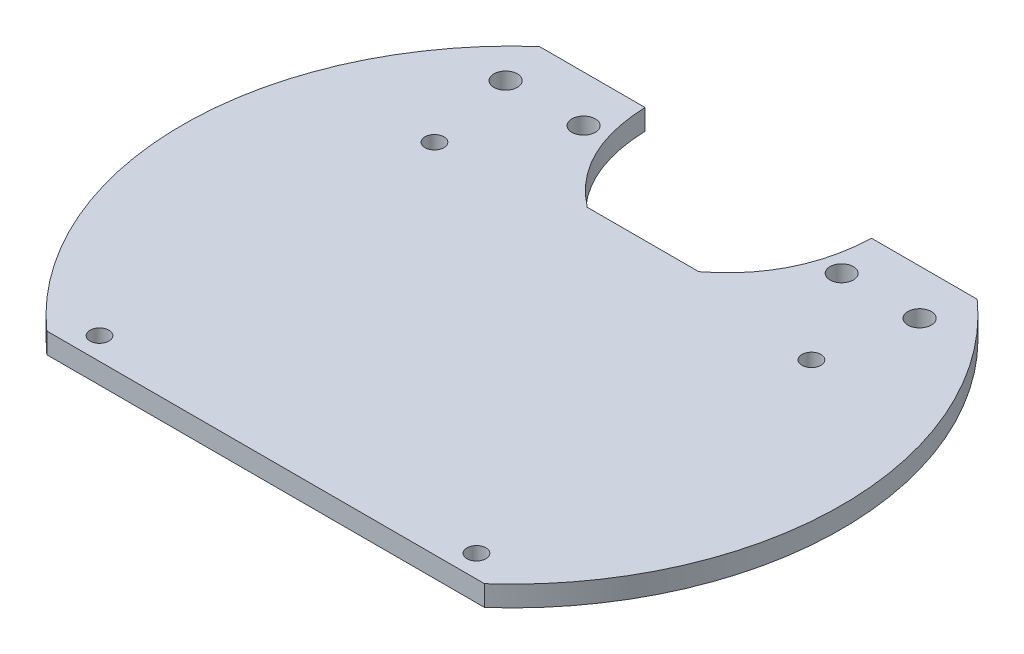
from build123d import *

# Parameters (mm, degrees)
SKETCH1_R           = 50.8
BOSS_EXTRUDE1_DEPTH = 3.175
SKETCH2_W           = 114.887790664
SKETCH2_H           = 17.737062418
CUT_EXTRUDE1_DEPTH  = 3.175
SKETCH6_R           = 1.4605
CUT_EXTRUDE2_DEPTH  = 3.175
SKETCH8_R           = 1.81159506
SKETCH8_R_2         = 1.809329071
SKETCH8_R_3         = 1.797728754
SKETCH8_R_4         = 1.815627059
CUT_EXTRUDE4_DEPTH  = 3.175


with BuildPart() as part:
    # Sketch1 → Boss-Extrude1 (new body)
    with BuildSketch(Plane(origin=(0, 0, 0), x_dir=(1, 0, 0), z_dir=(0, 1, 0))):
        Circle(SKETCH1_R)
    extrude(amount=BOSS_EXTRUDE1_DEPTH)

    # Sketch2 → Cut-Extrude1 (cut)
    with BuildSketch(Plane(origin=(0, 3.175, 0), x_dir=(1, 0, 0), z_dir=(0, 1, 0))):
        with BuildLine():
            Line((-53.141111112, 55.715142418), (61.746679552, 55.715142418))
            Line((61.746679552, 55.715142418), (61.746679552, 37.97808))
            Line((61.746679552, 37.97808), (17.466405486, 37.97808))
            add(Edge.make_bspline(
                [(17.466405486, 37.97808), (17.038082166, 26.714286782), (8.597103322, 20.19808)],
                knots=[0, 0, 0, 1, 1, 1], degree=2))
            Line((8.597103322, 20.19808), (-8.597103322, 20.19808))
            add(Edge.make_bspline(
                [(-17.466405486, 37.97808), (-17.038082166, 26.714286782), (-8.597103322, 20.19808)],
                knots=[0, 0, 0, 1, 1, 1], degree=2))
            Line((-17.466405486, 37.97808), (-53.141111112, 37.97808))
            Line((-53.141111112, 37.97808), (-53.141111112, 55.715142418))
        make_face()
        with Locations((4.30278422, -46.846611209)):
            Rectangle(SKETCH2_W, SKETCH2_H)
    extrude(amount=-CUT_EXTRUDE1_DEPTH, mode=Mode.SUBTRACT)

    # Sketch6 → Cut-Extrude2 (cut)
    with BuildSketch(Plane(origin=(0, 3.175, 0), x_dir=(1, 0, 0), z_dir=(0, 1, 0))):
        with Locations((-29.0576, 17.10182)):
            Circle(SKETCH6_R)
        with Locations((29.0576, 17.10182)):
            Circle(SKETCH6_R)
        with Locations((29.0576, -34.53638)):
            Circle(SKETCH6_R)
        with Locations((-29.0576, -34.53638)):
            Circle(SKETCH6_R)
    extrude(amount=-CUT_EXTRUDE2_DEPTH, mode=Mode.SUBTRACT)

    # Sketch8 → Cut-Extrude4 (cut)
    with BuildSketch(Plane.XZ):
        with Locations((-31.799566939, -30.819765523)):
            Circle(SKETCH8_R)
        with Locations((-19.785366939, -30.819765523)):
            Circle(SKETCH8_R_2)
        with Locations((19.830913185, -30.993944368)):
            Circle(SKETCH8_R_3)
        with Locations((31.845113185, -30.993944368)):
            Circle(SKETCH8_R_4)
    extrude(amount=-CUT_EXTRUDE4_DEPTH, mode=Mode.SUBTRACT)


solid = part.part
